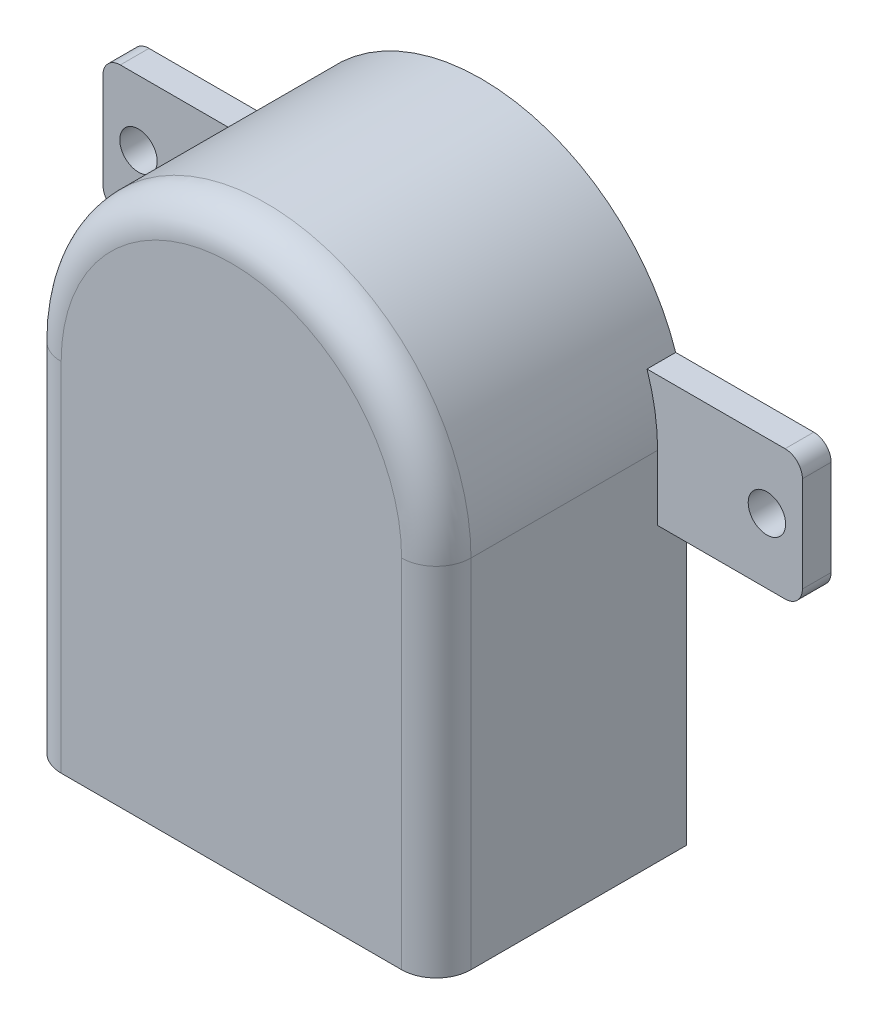
from build123d import *

# Parameters (mm, degrees)
BOSS_EXTRUDE1_DEPTH = 18.3
FILLET1_R           = 2.54
SKETCH2_W           = 13.138787008
SKETCH2_H           = 9.53
SKETCH2_R           = 1.37
BOSS_EXTRUDE2_DEPTH = 2.1
FILLET2_R           = 1.27
SKETCH3_R           = 4
CUT_EXTRUDE1_DEPTH  = 14
SKETCH4_W           = 14.5
SKETCH4_H           = 7.1
SKETCH4_W_2         = 0.64
SKETCH4_H_2         = 0.64
CUT_EXTRUDE2_DEPTH  = 6.35


with BuildPart() as part:
    # Sketch1 → Boss-Extrude1 (new body)
    with BuildSketch(Plane.XY):
        with BuildLine():
            Line((15, 0), (15, -26.1))
            Line((15, -26.1), (-15, -26.1))
            Line((-15, -26.1), (-15, 0))
            ThreePointArc((-15, 0), (0, 15), (15, 0))
        make_face()
    extrude(amount=BOSS_EXTRUDE1_DEPTH)

    # Fillet1
    fillet1_edges = [part.edges().sort_by_distance(p)[0] for p in [
        (15, -13.05, 18.3),
        (0, 15, 18.3),
        (-15, -13.05, 18.3),
    ]]
    fillet(fillet1_edges, radius=FILLET1_R)

    # Sketch2 → Boss-Extrude2 (add)
    with BuildSketch(Plane(origin=(0, 0, 0), x_dir=(-1, 0, 0), z_dir=(0, 0, -1))):
        with Locations((19.030606496, 0)):
            Rectangle(SKETCH2_W, SKETCH2_H)
        with Locations((23, 0)):
            Circle(SKETCH2_R, mode=Mode.SUBTRACT)
        with Locations((-19.030606496, 0)):
            Rectangle(SKETCH2_W, SKETCH2_H)
        with Locations((-23, 0)):
            Circle(SKETCH2_R, mode=Mode.SUBTRACT)
    extrude(amount=-BOSS_EXTRUDE2_DEPTH)

    # Fillet2
    fillet2_edges = [part.edges().sort_by_distance(p)[0] for p in [
        (-25.6, -4.765, 1.05),
        (-25.6, 4.765, 1.05),
        (25.6, 4.765, 1.05),
        (25.6, -4.765, 1.05),
    ]]
    fillet(fillet2_edges, radius=FILLET2_R)

    # Sketch3 → Cut-Extrude1 (cut)
    with BuildSketch(Plane(origin=(0, 0, 0), x_dir=(-1, 0, 0), z_dir=(0, 0, -1))):
        Circle(SKETCH3_R)
    extrude(amount=-CUT_EXTRUDE1_DEPTH, mode=Mode.SUBTRACT)

    # Sketch4 → Cut-Extrude2 (cut)
    with BuildSketch(Plane.XZ.offset(26.1)):
        with Locations((0, 5.68)):
            Rectangle(SKETCH4_W, SKETCH4_H)
        with Locations((-5.08, 5.13)):
            Rectangle(SKETCH4_W_2, SKETCH4_H_2, mode=Mode.SUBTRACT)
        with Locations((-2.54, 5.13)):
            Rectangle(SKETCH4_W_2, SKETCH4_H_2, mode=Mode.SUBTRACT)
        with Locations((0, 5.13)):
            Rectangle(SKETCH4_W_2, SKETCH4_H_2, mode=Mode.SUBTRACT)
        with Locations((2.54, 5.13)):
            Rectangle(SKETCH4_W_2, SKETCH4_H_2, mode=Mode.SUBTRACT)
        with Locations((5.08, 5.13)):
            Rectangle(SKETCH4_W_2, SKETCH4_H_2, mode=Mode.SUBTRACT)
    extrude(amount=-CUT_EXTRUDE2_DEPTH, mode=Mode.SUBTRACT)


solid = part.part
